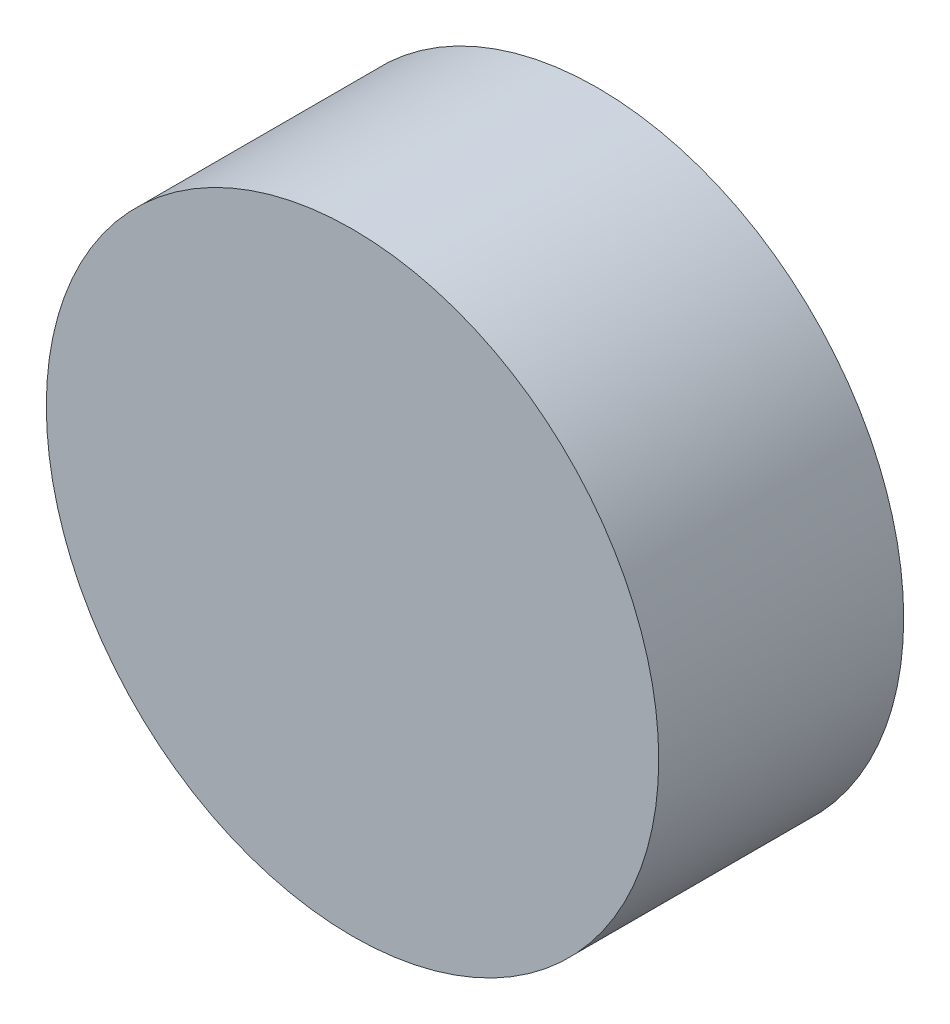
from build123d import *

# Parameters (mm, degrees)
SKETCH1_R           = 12.5
BOSS_EXTRUDE1_DEPTH = 10


with BuildPart() as part:
    # Sketch1 → Boss-Extrude1 (new body)
    with BuildSketch(Plane.XY):
        Circle(SKETCH1_R)
    extrude(amount=BOSS_EXTRUDE1_DEPTH)


solid = part.part
